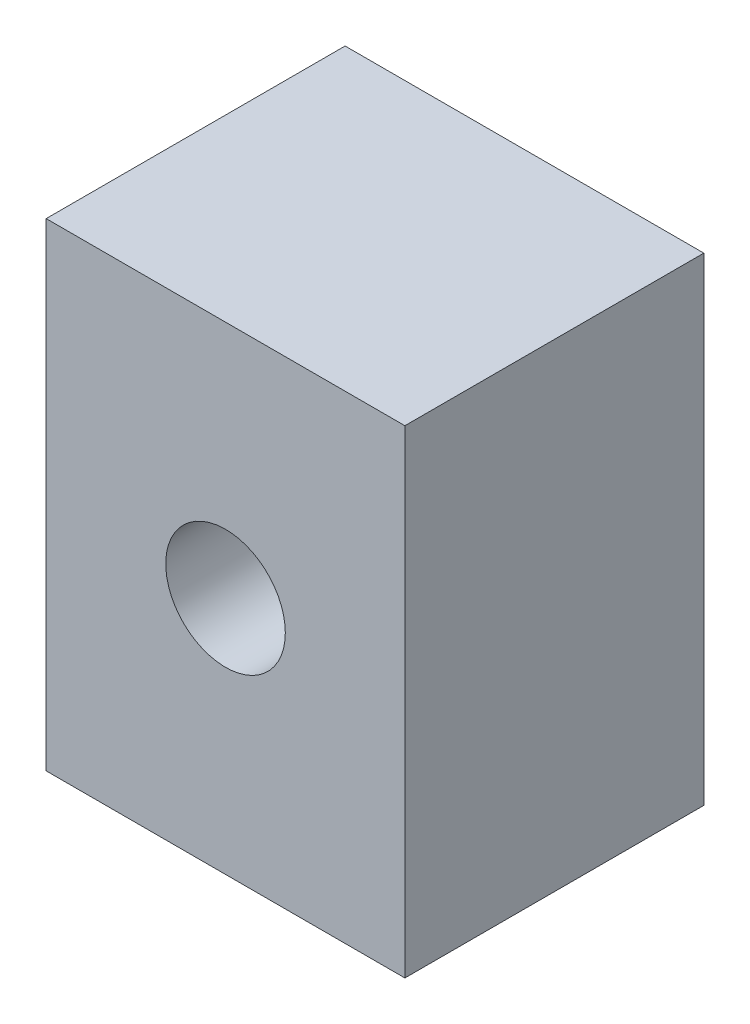
from build123d import *

# Parameters (mm, degrees)
SKETCH1_W           = 30
SKETCH1_H           = 25
BOSS_EXTRUDE1_DEPTH = 40
SKETCH2_R           = 5
CUT_EXTRUDE1_DEPTH  = 40


with BuildPart() as part:
    # Sketch1 → Boss-Extrude1 (new body)
    with BuildSketch(Plane(origin=(0, 0, 0), x_dir=(1, 0, 0), z_dir=(0, 1, 0))):
        Rectangle(SKETCH1_W, SKETCH1_H)
    extrude(amount=BOSS_EXTRUDE1_DEPTH)

    # Sketch2 → Cut-Extrude1 (cut)
    with BuildSketch(Plane.XY.offset(12.5)):
        with Locations((0, 20)):
            Circle(SKETCH2_R)
    extrude(amount=-CUT_EXTRUDE1_DEPTH, mode=Mode.SUBTRACT)


solid = part.part
